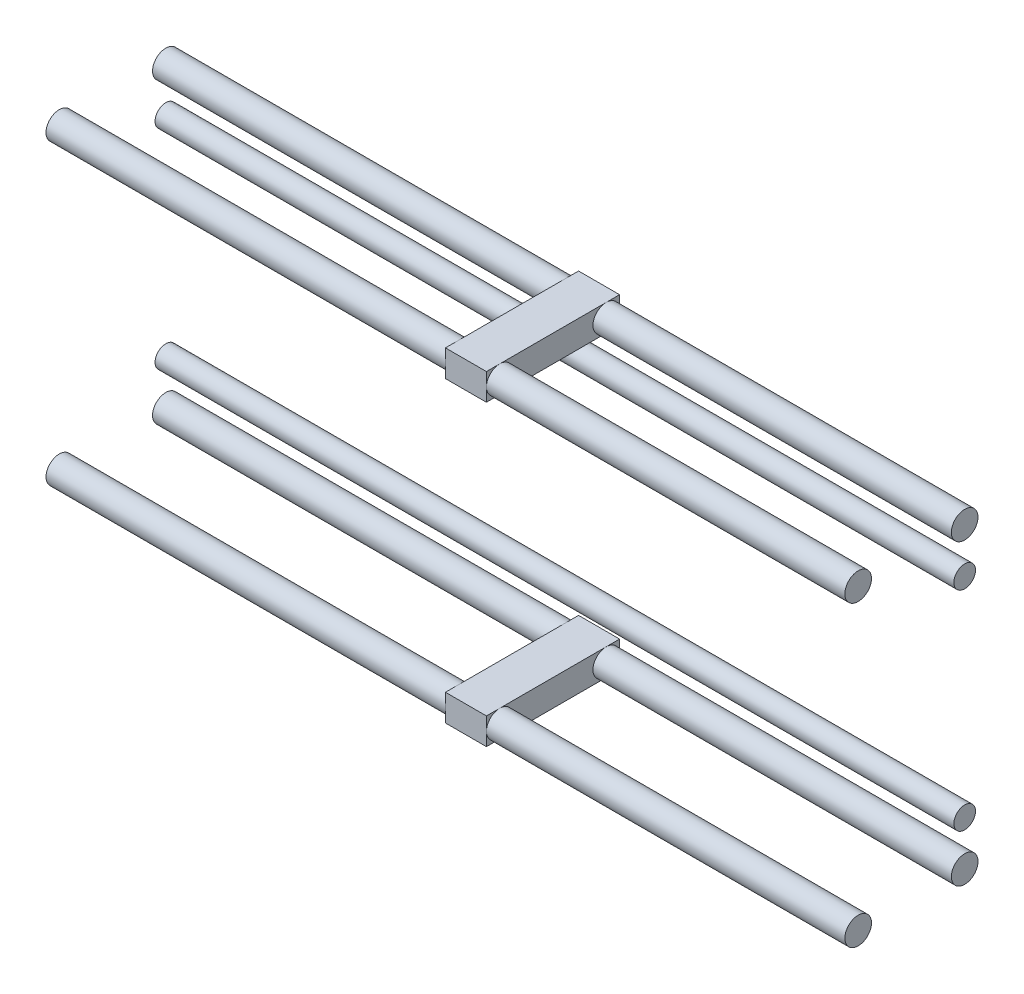
from build123d import *

# Parameters (mm, degrees)
CROQUIS1_W                = 25
CROQUIS1_H                = 5
SALIENTE_EXTRUIR1_DEPTH   = 7.7
SALIENTE_EXTRUIR1_2_DEPTH = 7.7
CROQUIS2_R                = 2.5
CROQUIS2_R_2              = 2.03
SALIENTE_EXTRUIR2_DEPTH   = 75


with BuildPart() as part:
    # Croquis1 → Saliente-Extruir1 (new body)
    with BuildSketch(Plane(origin=(0, 0, 0), x_dir=(0, 0, -1), z_dir=(1, 0, 0))):
        with Locations((2.128442445, 44.334232457)):
            Rectangle(CROQUIS1_W, CROQUIS1_H)
    extrude(amount=SALIENTE_EXTRUIR1_DEPTH)



with BuildPart() as body_2:
    # Croquis1 → Saliente-Extruir1 2 (new body)
    with BuildSketch(Plane(origin=(0, 0, 0), x_dir=(0, 0, -1), z_dir=(1, 0, 0))):
        with Locations((2.128442445, -11.665767543)):
            Rectangle(CROQUIS1_W, CROQUIS1_H)
    extrude(amount=SALIENTE_EXTRUIR1_2_DEPTH)


with BuildPart() as part_1:
    add(part.part)

    add(body_2.part)  # Saliente-Extruir2 merges body 2
    # Croquis2 → Saliente-Extruir2 (add, symmetric)
    with BuildSketch(Plane.ZY):
        with Locations((-12.128442445, 44.334232457)):
            Circle(CROQUIS2_R)
        with Locations((7.871557555, 44.334232457)):
            Circle(CROQUIS2_R)
        with Locations((7.871557555, -11.665767543)):
            Circle(CROQUIS2_R)
        with Locations((-12.128442445, -11.665767543)):
            Circle(CROQUIS2_R)
        with Locations((-12.128442445, 35.934232457)):
            Circle(CROQUIS2_R_2)
        with Locations((-12.128442445, -3.265767543)):
            Circle(CROQUIS2_R_2)
    extrude(amount=SALIENTE_EXTRUIR2_DEPTH, both=True)


solid = part_1.part
